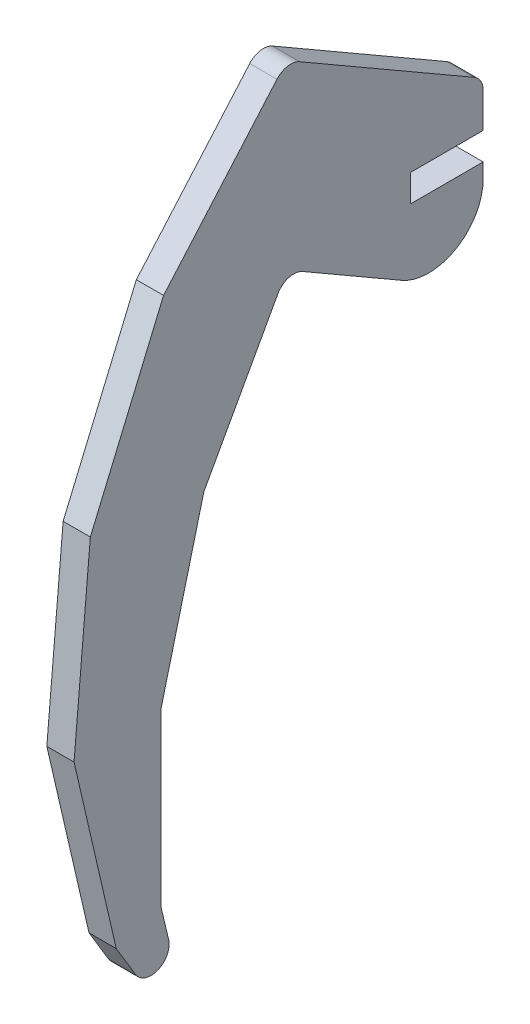
from build123d import *

# Parameters (mm, degrees)
BOSS_EXTRUDE1_DEPTH = 3


with BuildPart() as part:
    # Sketch1 → Boss-Extrude1 (new body)
    with BuildSketch(Plane(origin=(0, 0, 0), x_dir=(0, 0, -1), z_dir=(1, 0, 0))):
        with BuildLine():
            Line((-13.869045208, -53.846884879), (-13.019160894, -57.395119241))
            ThreePointArc((-13.019160894, -57.395119241), (-14.207117004, -59.712178989), (-16.67823792, -58.891467706))
            Line((-16.67823792, -58.891467706), (-18.79288086, -55.373986049))
            Line((-18.79288086, -55.373986049), (-23.446176246, -35.239966644))
            Line((-23.446176246, -35.239966644), (-21.649968985, -14.653428937))
            Line((-21.649968985, -14.653428937), (-13.580084357, 4.370473329))
            Line((-13.580084357, 4.370473329), (-1.081593074, 18.755177998))
            ThreePointArc((-1.081593074, 18.755177998), (0.097807511, 19.415947524), (1.428134813, 19.175465981))
            Line((1.428134813, 19.175465981), (20.650635095, 8.077350269))
            ThreePointArc((20.650635095, 8.077350269), (21.382685902, 7.345299462), (21.650635095, 6.345299462))
            Line((21.650635095, 6.345299462), (21.650635095, 2.5))
            Line((21.650635095, 2.5), (13.650635095, 2.5))
            Line((13.650635095, 2.5), (13.650635095, -0.5))
            Line((13.650635095, -0.5), (21.650635095, -0.5))
            Line((21.650635095, -0.5), (21.650635095, -2.107695155))
            ThreePointArc((21.650635095, -2.107695155), (18.650635095, -7.303847577), (12.650635095, -7.303847577))
            Line((12.650635095, -7.303847577), (1.767371596, -1.020392466))
            ThreePointArc((1.767371596, -1.020392466), (0.230262068, -0.825914438), (-0.984510925, -1.787607726))
            Line((-0.984510925, -1.787607726), (-9.132781883, -16.582681858))
            Line((-9.132781883, -16.582681858), (-13.854695348, -34.915618767))
            Line((-13.854695348, -34.915618767), (-13.869045208, -53.846884879))
        make_face()
    extrude(amount=BOSS_EXTRUDE1_DEPTH)


solid = part.part
